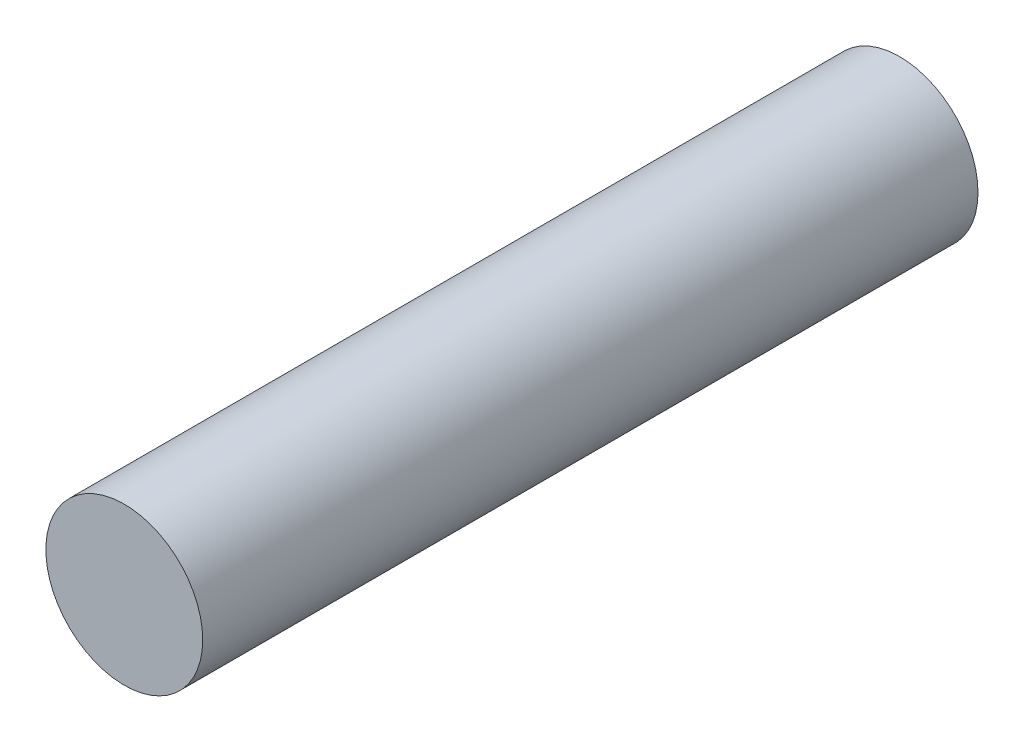
from build123d import *

# Parameters (mm, degrees)
SKETCH1_R      = 3.302
EXTRUDE1_DEPTH = 32.639


with BuildPart() as part:
    # Sketch1 → Extrude1 (new body)
    with BuildSketch(Plane.XY):
        Circle(SKETCH1_R)
    extrude(amount=EXTRUDE1_DEPTH)


solid = part.part
